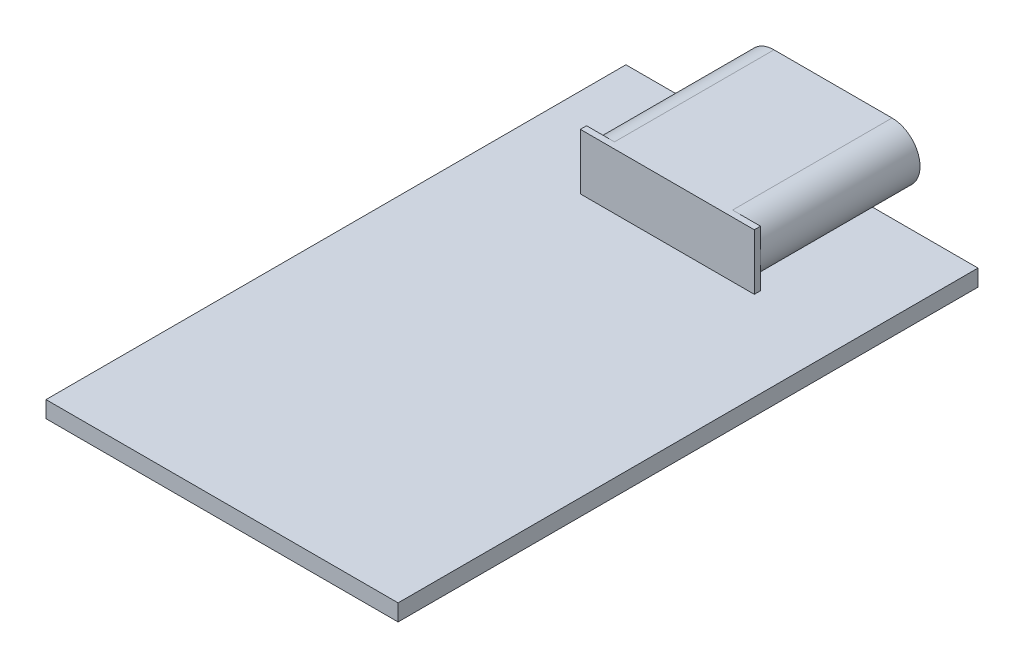
from build123d import *

# Parameters (mm, degrees)
SKETCH1_W           = 17
SKETCH1_H           = 28
BOSS_EXTRUDE1_DEPTH = 0.8
SKETCH3_W           = 8.4
SKETCH3_H           = 8
BOSS_EXTRUDE2_DEPTH = 2.7
CUT_EXTRUDE1_DEPTH  = 7.7


with BuildPart() as part:
    # Sketch1 → Boss-Extrude1 (new body)
    with BuildSketch(Plane(origin=(0, 0, 0), x_dir=(1, 0, 0), z_dir=(0, 1, 0))):
        Rectangle(SKETCH1_W, SKETCH1_H)
    extrude(amount=BOSS_EXTRUDE1_DEPTH)

    # Sketch3 → Boss-Extrude2 (add)
    with BuildSketch(Plane(origin=(0, 0.8, 0), x_dir=(1, 0, 0), z_dir=(0, 1, 0))):
        with Locations((0, 11.5)):
            Rectangle(SKETCH3_W, SKETCH3_H)
    extrude(amount=BOSS_EXTRUDE2_DEPTH)

    # Sketch4 → Cut-Extrude1 (cut)
    with BuildSketch(Plane(origin=(0, 0, -15.5), x_dir=(-1, 0, 0), z_dir=(0, 0, -1))):
        with BuildLine():
            ThreePointArc((-4.2, 2.15), (-3.804594155, 3.104594155), (-2.85, 3.5))
            Line((-2.85, 3.5), (-4.2, 3.5))
            Line((-4.2, 3.5), (-4.2, 2.15))
        make_face()
        with BuildLine():
            ThreePointArc((-2.85, 0.8), (-3.804594155, 1.195405845), (-4.2, 2.15))
            Line((-4.2, 2.15), (-4.2, 0.8))
            Line((-4.2, 0.8), (-2.85, 0.8))
        make_face()
        with BuildLine():
            Line((4.2, 0.8), (4.2, 2.15))
            ThreePointArc((4.2, 2.15), (3.804594155, 1.195405845), (2.85, 0.8))
            Line((2.85, 0.8), (4.2, 0.8))
        make_face()
        with BuildLine():
            Line((4.2, 3.5), (2.85, 3.5))
            ThreePointArc((2.85, 3.5), (3.804594155, 3.104594155), (4.2, 2.15))
            Line((4.2, 2.15), (4.2, 3.5))
        make_face()
        with BuildLine():
            Line((-2.85, 1.05), (2.85, 1.05))
            ThreePointArc((2.85, 1.05), (3.95, 2.15), (2.85, 3.25))
            Line((2.85, 3.25), (-2.85, 3.25))
            ThreePointArc((-2.85, 3.25), (-3.95, 2.15), (-2.85, 1.05))
        make_face()
        with BuildLine():
            ThreePointArc((2.85, 1.8), (3.2, 2.15), (2.85, 2.5))
            Line((2.85, 2.5), (-2.85, 2.5))
            ThreePointArc((-2.85, 2.5), (-3.2, 2.15), (-2.85, 1.8))
            Line((-2.85, 1.8), (2.85, 1.8))
        make_face(mode=Mode.SUBTRACT)
    extrude(amount=-CUT_EXTRUDE1_DEPTH, mode=Mode.SUBTRACT)


solid = part.part
